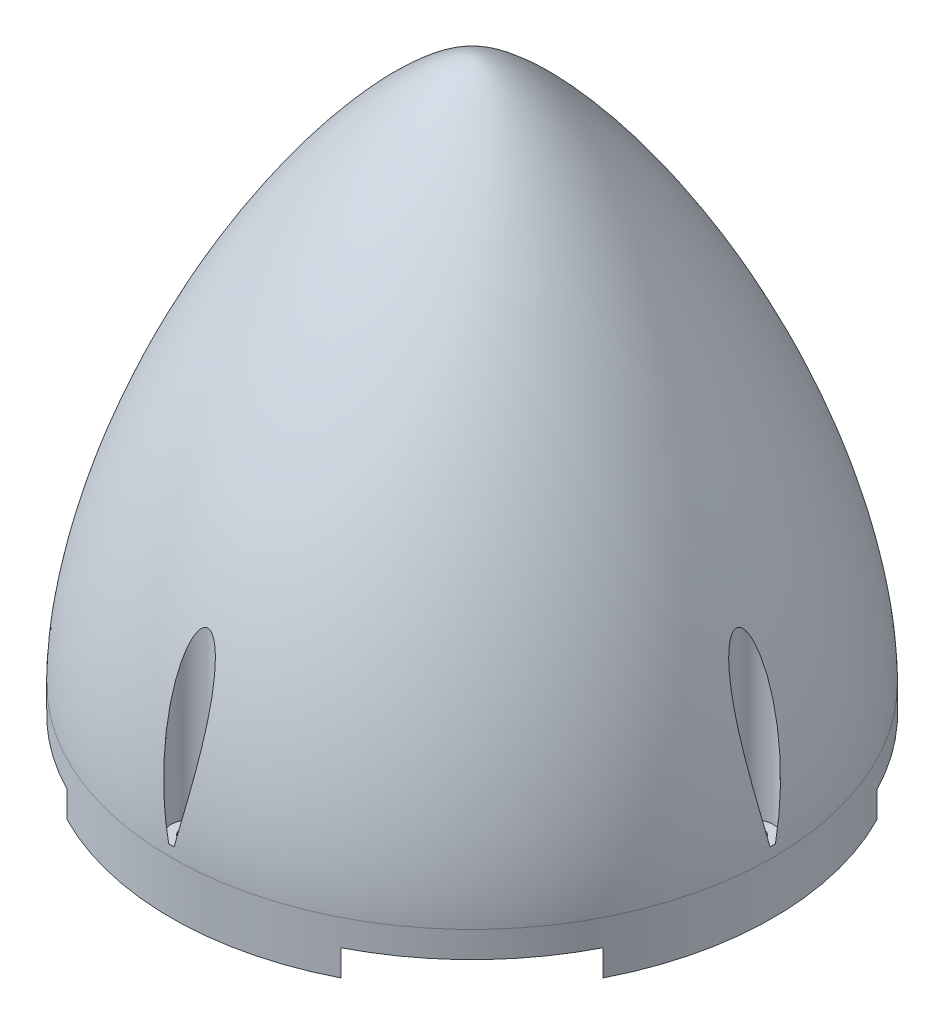
from build123d import *

# Parameters (mm, degrees)
SKETCH3_R           = 57.5
BOSS_EXTRUDE1_DEPTH = 5
BOSS_EXTRUDE2_DEPTH = 5
CIRPATTERN2_COUNT   = 4
SKETCH7_R           = 1.75
CUT_EXTRUDE1_DEPTH  = 12
SKETCH8_R           = 3.5
CUT_EXTRUDE2_DEPTH  = 131.155096992
CIRPATTERN1_COUNT   = 4


with BuildPart() as part:
    # Sketch1 → Revolve2 (revolve)
    with BuildSketch(Plane.XY):
        with BuildLine():
            Line((47.5, 0), (57.5, 0))
            add(Edge.make_bspline(
                [(57.5, 0), (57.5, 22.486866931), (44.523412509, 66.822797193), (11.090180384, 103.62602634), (0, 103.62602634)],
                knots=[0, 0, 0, 0, 0, 1, 1, 1, 1, 1], degree=4))
            Line((0, 103.62602634), (0, 93.62602634))
            add(Edge.make_bspline(
                [(47.5, 0), (47.5, 22.486866931), (34.523412509, 66.822797193), (10.174500673, 93.62602634), (0, 93.62602634)],
                knots=[0, 0, 0, 0, 0, 1, 1, 1, 1, 1], degree=4))
        make_face()
    revolve(axis=Axis((0, 0, 0), (0, 1, 0)))

    # Sketch3 → Boss-Extrude1 (add)
    with BuildSketch(Plane.XZ):
        Circle(SKETCH3_R)
    extrude(amount=BOSS_EXTRUDE1_DEPTH)

    # Sketch9 → Boss-Extrude2 (add)
    with BuildSketch(Plane.XZ.offset(5)):
        with BuildLine():
            Line((26.189468851, -51.189468851), (0, -25))
            Line((0, -25), (-26.189468851, -51.189468851))
            ThreePointArc((-26.189468851, -51.189468851), (0, -57.5), (26.189468851, -51.189468851))
        make_face()
    boss_extrude2 = extrude(amount=BOSS_EXTRUDE2_DEPTH)

    # CirPattern2: Boss-Extrude2 ×4 about axis
    cirpattern2_axis = Axis((0, -5, 0), (0, -1, 0))
    for i in range(1, CIRPATTERN2_COUNT):
        add(boss_extrude2.rotate(cirpattern2_axis, i * 360 / CIRPATTERN2_COUNT))

    # Sketch7 → Cut-Extrude1 (cut)
    with BuildSketch(Plane.XZ.offset(10)):
        with Locations((-54, 0)):
            Circle(SKETCH7_R)
    cut_extrude1 = extrude(amount=-CUT_EXTRUDE1_DEPTH, mode=Mode.SUBTRACT)

    # Sketch8 → Cut-Extrude2 (cut, through all)
    with BuildSketch(Plane.XZ.offset(-2)):
        with Locations((-54, 0)):
            Circle(SKETCH8_R)
    cut_extrude2 = extrude(amount=-CUT_EXTRUDE2_DEPTH, mode=Mode.SUBTRACT)

    # CirPattern1: Cut-Extrude1, Cut-Extrude2 ×4 about axis
    cirpattern1_axis = Axis((0, 0, 0), (0, -1, 0))
    add([cut_extrude1.rotate(cirpattern1_axis, i * 360 / CIRPATTERN1_COUNT) for i in range(1, CIRPATTERN1_COUNT)], mode=Mode.SUBTRACT)
    add([cut_extrude2.rotate(cirpattern1_axis, i * 360 / CIRPATTERN1_COUNT) for i in range(1, CIRPATTERN1_COUNT)], mode=Mode.SUBTRACT)


solid = part.part
